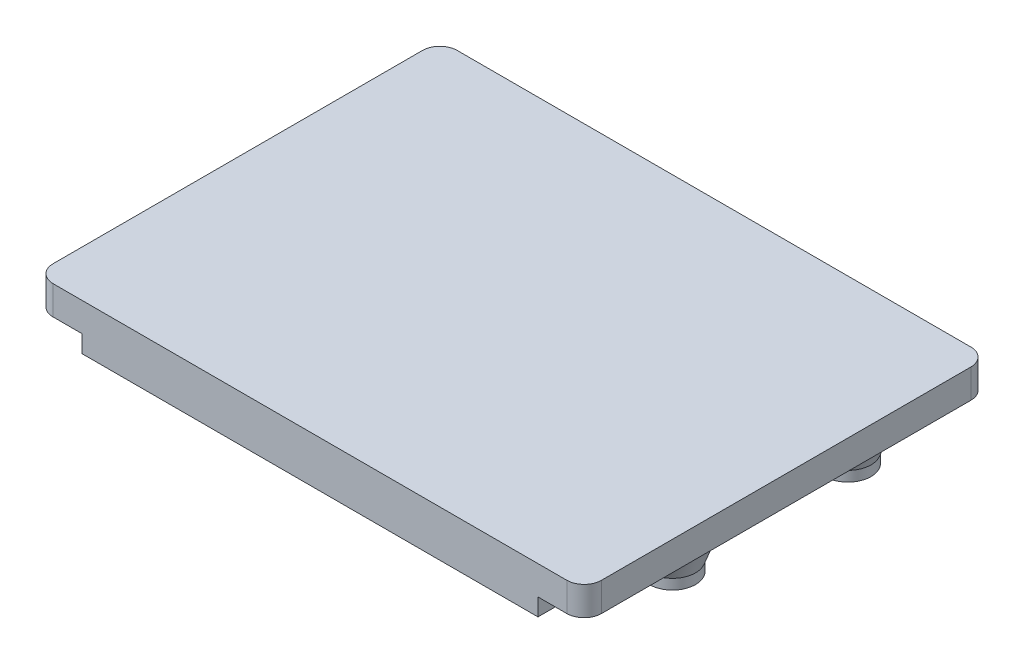
from build123d import *

# Parameters (mm, degrees)
ESQUISSE1_W      = 95
ESQUISSE1_H      = 70
EXTRUSION1_DEPTH = 5
ESQUISSE2_W      = 79
ESQUISSE2_H      = 5
ESQUISSE2_W_2    = 58
ESQUISSE2_W_3    = 5
ESQUISSE2_H_2    = 9
EXTRUSION2_DEPTH = 3
ESQUISSE3_W      = 5
ESQUISSE3_H      = 9
EXTRUSION3_DEPTH = 5
CONG_1_R         = 3
ESQUISSE5_R      = 4
ESQUISSE5_R_2    = 1.6
EXTRUSION4_DEPTH = 10
CHANFREIN1_SIZE  = 3
CHANFREIN1_SIZE2 = 8.242432258


with BuildPart() as part:
    # Esquisse1 → Extrusion1 (new body)
    with BuildSketch(Plane(origin=(0, 0, 0), x_dir=(1, 0, 0), z_dir=(0, 1, 0))):
        Rectangle(ESQUISSE1_W, ESQUISSE1_H)
    extrude(amount=EXTRUSION1_DEPTH)

    # Esquisse2 → Extrusion2 (add)
    with BuildSketch(Plane.XZ):
        with Locations((0, 32.5)):
            Rectangle(ESQUISSE2_W, ESQUISSE2_H)
        with Locations((0.5, -32.5)):
            Rectangle(ESQUISSE2_W_2, ESQUISSE2_H)
        with Locations((-45, -10)):
            Rectangle(ESQUISSE2_W_3, ESQUISSE2_H_2)
    extrude(amount=EXTRUSION2_DEPTH)

    # Esquisse3 → Extrusion3 (add)
    with BuildSketch(Plane.XZ):
        with Locations((-45, 5)):
            Rectangle(ESQUISSE3_W, ESQUISSE3_H)
    extrude(amount=EXTRUSION3_DEPTH)

    # Congé1
    cong_1_edges = [part.edges().sort_by_distance(p)[0] for p in [
        (47.5, 2.5, -35),
        (-47.5, 2.5, -35),
        (-47.5, 2.5, 35),
        (47.5, 2.5, 35),
    ]]
    fillet(cong_1_edges, radius=CONG_1_R)

    # Esquisse5 → Extrusion4 (add)
    with BuildSketch(Plane.XZ):
        with Locations((-25.5, 10.5)):
            Circle(ESQUISSE5_R)
        with Locations((-25.5, 10.5)):
            Circle(ESQUISSE5_R_2, mode=Mode.SUBTRACT)
        with Locations((37.3, 9.5)):
            Circle(ESQUISSE5_R)
        with Locations((37.3, 9.5)):
            Circle(ESQUISSE5_R_2, mode=Mode.SUBTRACT)
        with Locations((36.3, -21.9)):
            Circle(ESQUISSE5_R)
        with Locations((36.3, -21.9)):
            Circle(ESQUISSE5_R_2, mode=Mode.SUBTRACT)
        with Locations((-36.5, -23.5)):
            Circle(ESQUISSE5_R)
        with Locations((-36.5, -23.5)):
            Circle(ESQUISSE5_R_2, mode=Mode.SUBTRACT)
    extrude(amount=EXTRUSION4_DEPTH)

    # Chanfrein1
    chanfrein1_edges = [part.edges().sort_by_distance(p)[0] for p in [
        (-29.5, 0, 10.5),
        (32.3, 0, -21.9),
        (-40.5, 0, -23.5),
        (33.3, 0, 9.5),
    ]]
    chanfrein1_side = [part.faces().sort_by_distance(p)[0] for p in [
        (0.586268245, 0, -0.3372194),
    ]]
    chamfer(chanfrein1_edges, length=CHANFREIN1_SIZE, length2=CHANFREIN1_SIZE2, reference=chanfrein1_side[0])


solid = part.part
